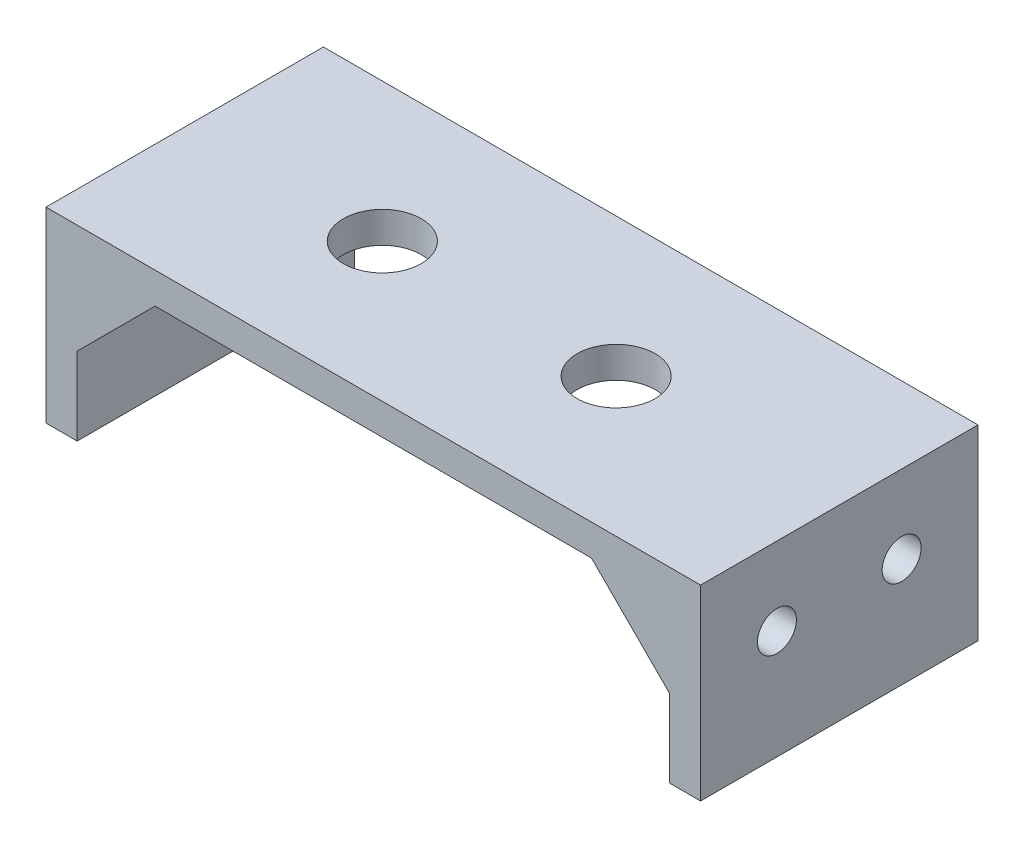
from build123d import *

# Parameters (mm, degrees)
SKETCH2_W           = 42
SKETCH2_H           = 17.8
BOSS_EXTRUDE1_DEPTH = 2
SKETCH3_W           = 2
SKETCH3_H           = 17.8
BOSS_EXTRUDE2_DEPTH = 10
BOSS_EXTRUDE3_DEPTH = 2
SKETCH5_R           = 2.5
CUT_EXTRUDE1_DEPTH  = 2
SKETCH6_R           = 1.25
CUT_EXTRUDE2_DEPTH  = 2


with BuildPart() as part:
    # Sketch2 → Boss-Extrude1 (new body)
    with BuildSketch(Plane(origin=(0, 0, 0), x_dir=(1, 0, 0), z_dir=(0, 1, 0))):
        Rectangle(SKETCH2_W, SKETCH2_H)
    extrude(amount=BOSS_EXTRUDE1_DEPTH)

    # Sketch3 → Boss-Extrude2 (add)
    with BuildSketch(Plane.XZ):
        with Locations((-20, 0)):
            Rectangle(SKETCH3_W, SKETCH3_H)
        with Locations((20, 0)):
            Rectangle(SKETCH3_W, SKETCH3_H)
    extrude(amount=BOSS_EXTRUDE2_DEPTH)

    # Sketch4 → Boss-Extrude3 (add)
    with BuildSketch(Plane.XY.offset(8.9)):
        Polygon((-19, 0), (-14, 0), (-19, -5), align=None)
        Polygon((19, -5), (14, 0), (19, 0), align=None)
    boss_extrude3 = extrude(amount=-BOSS_EXTRUDE3_DEPTH)

    # Mirror1: Boss-Extrude3 across plane
    add(boss_extrude3.mirror(Plane.XY))

    # Sketch5 → Cut-Extrude1 (cut)
    with BuildSketch(Plane.XZ):
        with Locations((-8.319906625, 0)):
            Circle(SKETCH5_R)
        with Locations((6.680093375, 0)):
            Circle(SKETCH5_R)
    extrude(amount=-CUT_EXTRUDE1_DEPTH, mode=Mode.SUBTRACT)

    # Sketch6 → Cut-Extrude2 (cut)
    with BuildSketch(Plane(origin=(-19, 0, 0), x_dir=(0, 0, -1), z_dir=(1, 0, 0))):
        with Locations((-4, -3)):
            Circle(SKETCH6_R)
        with Locations((4, -3)):
            Circle(SKETCH6_R)
    cut_extrude2 = extrude(amount=-CUT_EXTRUDE2_DEPTH, mode=Mode.SUBTRACT)

    # Mirror2: Cut-Extrude2 across plane
    add(cut_extrude2.mirror(Plane(origin=(0, 0, 0), x_dir=(0, 0, 1), z_dir=(1, 0, 0))), mode=Mode.SUBTRACT)


solid = part.part
